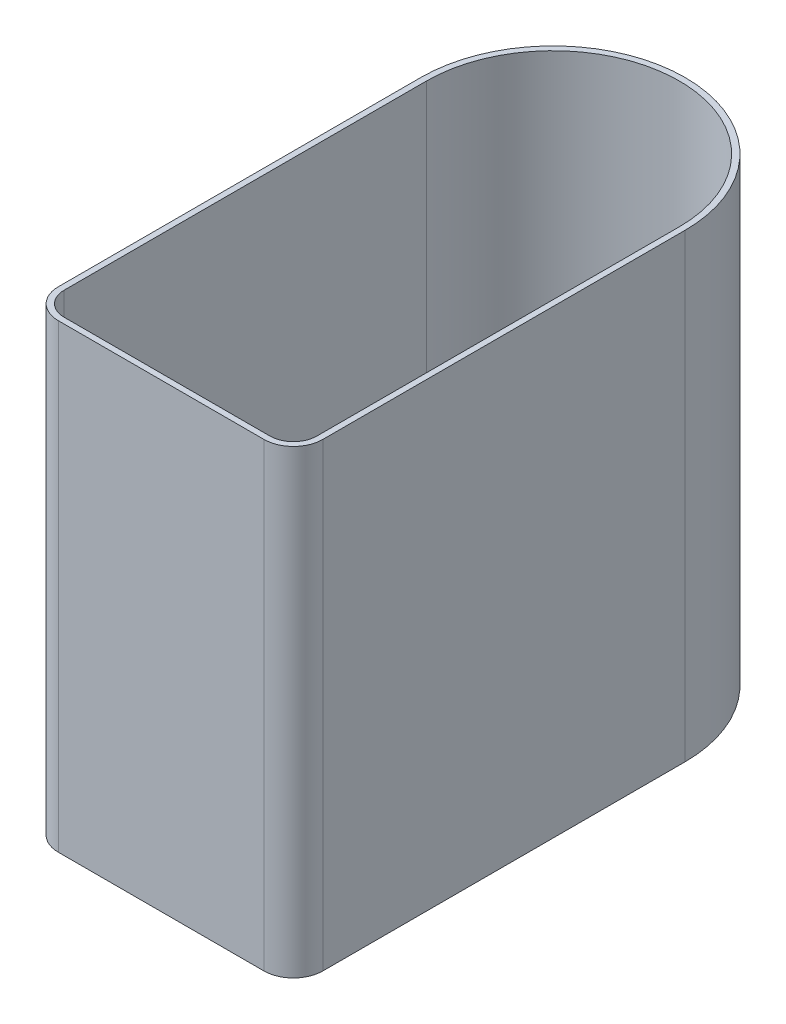
from build123d import *

# Parameters (mm, degrees)
BOSS_EXTRUDE1_DEPTH = 235
SHELL1_T            = -3


with BuildPart() as part:
    # Sketch1 → Boss-Extrude1 (new body)
    with BuildSketch(Plane(origin=(0, 0, 0), x_dir=(1, 0, 0), z_dir=(0, 1, 0))):
        with BuildLine():
            Line((52.5, -100), (-52.5, -100))
            ThreePointArc((-52.5, -100), (-63.106601718, -95.606601718), (-67.5, -85))
            Line((-67.5, -85), (-67.5, 100))
            ThreePointArc((-67.5, 100), (0, 167.5), (67.5, 100))
            Line((67.5, 100), (67.5, -85))
            ThreePointArc((67.5, -85), (63.106601718, -95.606601718), (52.5, -100))
        make_face()
    extrude(amount=BOSS_EXTRUDE1_DEPTH)

    # Shell1
    shell1_openings = [part.faces().sort_by_distance(p)[0] for p in [
        (0, 235, 18.118867239),
    ]]
    offset(amount=SHELL1_T, openings=shell1_openings, kind=Kind.INTERSECTION)


solid = part.part
